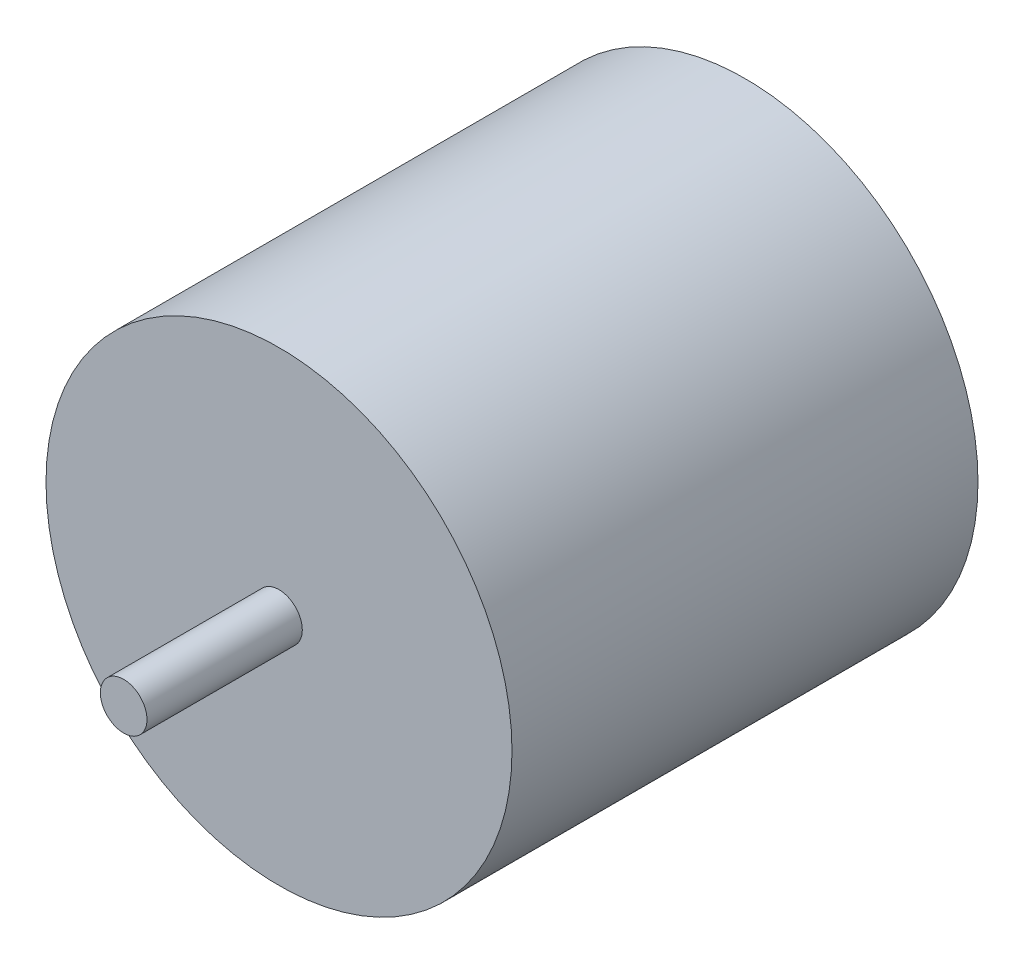
from build123d import *

# Parameters (mm, degrees)
SKETCH1_R           = 15
BOSS_EXTRUDE1_DEPTH = 30
SKETCH2_R           = 1.5
BOSS_EXTRUDE2_DEPTH = 10
SKETCH3_W           = 2
SKETCH3_H           = 4
BOSS_EXTRUDE3_DEPTH = 5


with BuildPart() as part:
    # Sketch1 → Boss-Extrude1 (new body)
    with BuildSketch(Plane.XY):
        Circle(SKETCH1_R)
    extrude(amount=BOSS_EXTRUDE1_DEPTH)

    # Sketch2 → Boss-Extrude2 (add)
    with BuildSketch(Plane.XY.offset(30)):
        Circle(SKETCH2_R)
    extrude(amount=BOSS_EXTRUDE2_DEPTH)

    # Sketch3 → Boss-Extrude3 (add)
    with BuildSketch(Plane(origin=(0, 0, 0), x_dir=(-1, 0, 0), z_dir=(0, 0, -1))):
        with Locations((-6, 0.376613429)):
            Rectangle(SKETCH3_W, SKETCH3_H)
        with Locations((6, 0.376613429)):
            Rectangle(SKETCH3_W, SKETCH3_H)
    extrude(amount=BOSS_EXTRUDE3_DEPTH)


solid = part.part
